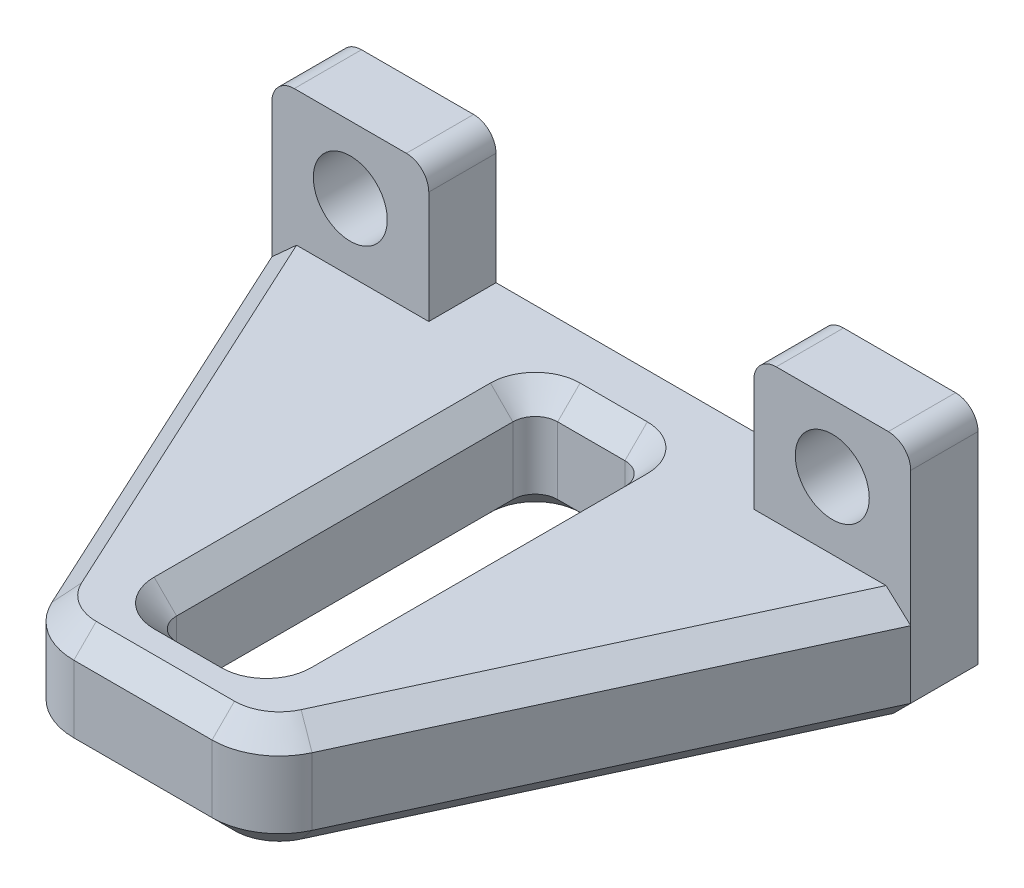
from build123d import *

# Parameters (mm, degrees)
SKETCH_1_R          = 1.65
EXTRUDE_1_DEPTH     = 3
EXTRUDE_2_DEPTH     = 5
SKETCH_3_W          = 5
SKETCH_3_H          = 17
CUT_EXTRUDE_1_DEPTH = 12
FILLET_1_R          = 3
FILLET_2_R          = 1
CHAMFER_1_SIZE      = 1
FILLET_3_R          = 1
CHAMFER_2_SIZE      = 1


with BuildPart() as part:
    # ｽｹｯﾁ1 → ﾎﾞｽ - 押し出し1 (new body)
    with BuildSketch(Plane.XY):
        Polygon((-7.25, -3), (7.25, -3), (7.25, 3), (14.25, 3), (14.25, -8), (-14.25, -8), (-14.25, 3), (-7.25, 3), align=None)
        with Locations((10.75, 0)):
            Circle(SKETCH_1_R, mode=Mode.SUBTRACT)
        with Locations((-10.75, 0)):
            Circle(SKETCH_1_R, mode=Mode.SUBTRACT)
    extrude(amount=EXTRUDE_1_DEPTH)

    # ｽｹｯﾁ2 → ﾎﾞｽ - 押し出し2 (add)
    with BuildSketch(Plane.XZ.offset(8)):
        Polygon((-14.25, 3), (-5, 23), (5, 23), (14.25, 3), align=None)
    extrude(amount=-EXTRUDE_2_DEPTH)

    # ｽｹｯﾁ3 → ｶｯﾄ - 押し出し1 (cut, through all)
    with BuildSketch(Plane.XZ.offset(8)):
        with Locations((0, 11.5)):
            Rectangle(SKETCH_3_W, SKETCH_3_H)
    extrude(amount=-CUT_EXTRUDE_1_DEPTH, mode=Mode.SUBTRACT)

    # ﾌｨﾚｯﾄ1
    fillet_1_edges = [part.edges().sort_by_distance(p)[0] for p in [
        (-5, -5.5, 23),
        (5, -5.5, 23),
    ]]
    fillet(fillet_1_edges, radius=FILLET_1_R)

    # ﾌｨﾚｯﾄ2
    fillet_2_edges = [part.edges().sort_by_distance(p)[0] for p in [
        (7.25, 3, 1.5),
        (14.25, 3, 1.5),
        (-14.25, 3, 1.5),
        (-7.25, 3, 1.5),
    ]]
    fillet(fillet_2_edges, radius=FILLET_2_R)

    # 面取り1
    chamfer_1_edges = [part.edges().sort_by_distance(p)[0] for p in [
        (14.25, -8, 1.5),
        (-14.25, -8, 1.5),
        (10.027529355, -3, 12.12966626),
        (10.027529355, -8, 12.12966626),
        (0, -8, 23),
        (0, -3, 23),
        (-10.027529355, -8, 12.12966626),
        (4.69803687, -8, 22.527646886),
        (-4.69803687, -8, 22.527646886),
        (-10.027529355, -3, 12.12966626),
        (4.69803687, -3, 22.527646886),
        (-4.69803687, -3, 22.527646886),
    ]]
    chamfer(chamfer_1_edges, length=CHAMFER_1_SIZE)

    # ﾌｨﾚｯﾄ3
    fillet_3_edges = [part.edges().sort_by_distance(p)[0] for p in [
        (2.5, -5.5, 20),
        (2.5, -5.5, 3),
        (-2.5, -5.5, 3),
        (-2.5, -5.5, 20),
    ]]
    fillet(fillet_3_edges, radius=FILLET_3_R)

    # 面取り2
    chamfer_2_edges = [part.edges().sort_by_distance(p)[0] for p in [
        (2.5, -8, 11.5),
        (2.5, -3, 11.5),
        (0, -8, 3),
        (0, -3, 3),
        (-2.5, -8, 11.5),
        (-2.5, -3, 11.5),
        (0, -8, 20),
        (0, -3, 20),
        (2.207106781, -8, 3.292893219),
        (2.207106781, -3, 3.292893219),
        (-2.207106781, -8, 3.292893219),
        (-2.207106781, -3, 3.292893219),
        (2.207106781, -8, 19.707106781),
        (2.207106781, -3, 19.707106781),
        (-2.207106781, -8, 19.707106781),
        (-2.207106781, -3, 19.707106781),
    ]]
    chamfer(chamfer_2_edges, length=CHAMFER_2_SIZE)


solid = part.part
